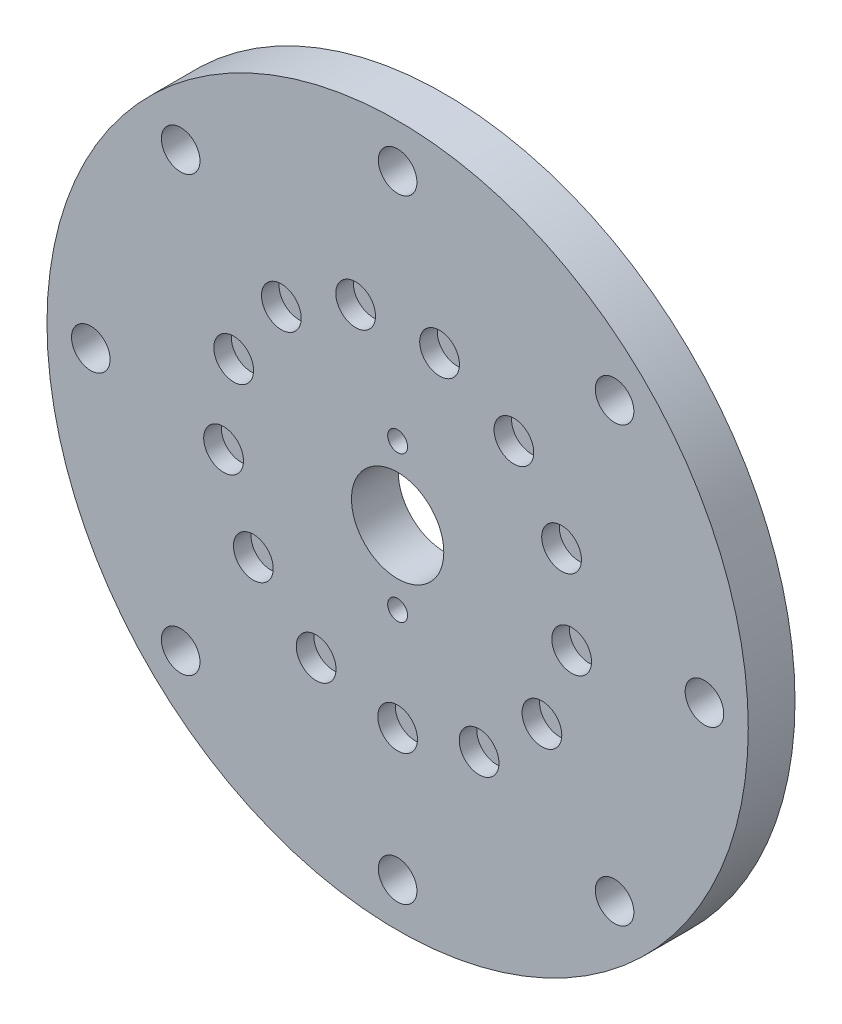
from build123d import *

# Parameters (mm, degrees)
SKETCH1_R            = 60
SKETCH1_R_2          = 7.9
BOSS_EXTRUDE1_DEPTH  = 8
SKETCH2_R            = 1.7
CUT_EXTRUDE1_DEPTH   = 9
SKETCH3_R            = 3.4
CUT_EXTRUDE2_DEPTH   = 3
M6_CLEARANCE_HOLE1_D = 6.6


with BuildPart() as part:
    # Sketch1 → Boss-Extrude1 (new body)
    with BuildSketch(Plane.XY):
        Circle(SKETCH1_R)
        Circle(SKETCH1_R_2, mode=Mode.SUBTRACT)
    extrude(amount=BOSS_EXTRUDE1_DEPTH)

    # Sketch2 → Cut-Extrude1 (cut, through all)
    with BuildSketch(Plane.XY.offset(8)):
        with Locations((0, 12.5)):
            Circle(SKETCH2_R)
        with Locations((0, -12.5)):
            Circle(SKETCH2_R)
    extrude(amount=-CUT_EXTRUDE1_DEPTH, mode=Mode.SUBTRACT)

    # Sketch3 → Cut-Extrude2 (cut)
    with BuildSketch(Plane.XY.offset(8)):
        with Locations((29.781294677, -3.615866061)):
            Circle(SKETCH3_R)
        with Locations((24.689650078, -17.041748121)):
            Circle(SKETCH3_R)
        with Locations((13.941904189, -26.563571062)):
            Circle(SKETCH3_R)
        with Locations((0.000236068, -29.999999999)):
            Circle(SKETCH3_R)
        with Locations((-13.941486133, -26.563790475)):
            Circle(SKETCH3_R)
        with Locations((-24.689381874, -17.042136682)):
            Circle(SKETCH3_R)
        with Locations((-29.781237767, -3.616334754)):
            Circle(SKETCH3_R)
        with Locations((-28.050570991, 10.637925883)):
            Circle(SKETCH3_R)
        with Locations((-19.893856446, 22.455165902)):
            Circle(SKETCH3_R)
        with Locations((-7.179699137, 29.128198027)):
            Circle(SKETCH3_R)
        with Locations((7.17924072, 29.128311017)):
            Circle(SKETCH3_R)
        with Locations((19.893503047, 22.455478987)):
            Circle(SKETCH3_R)
        with Locations((28.050403569, 10.638367338)):
            Circle(SKETCH3_R)
    extrude(amount=-CUT_EXTRUDE2_DEPTH, mode=Mode.SUBTRACT)

    # M6 Clearance Hole1 (through all)
    with Locations(Plane.XY.offset(8)):
        with Locations((-37.123106012, 37.123106012), (0, 52.5), (37.123106012, 37.123106012), (52.5, 0), (37.123106012, -37.123106012), (0, -52.5), (-37.123106012, -37.123106012), (-52.5, 0)):
            Hole(M6_CLEARANCE_HOLE1_D / 2)


solid = part.part
